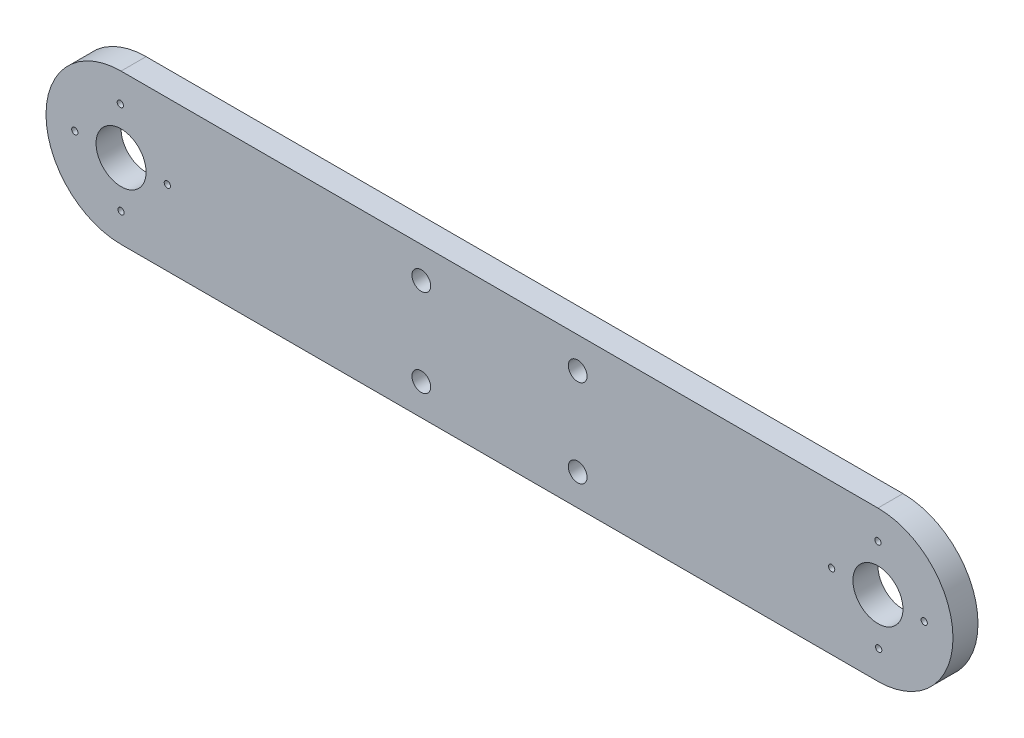
from build123d import *

# Parameters (mm, degrees)
SKETCH1_R           = 4
SKETCH1_R_2         = 0.5
SKETCH1_R_3         = 1.5
BOSS_EXTRUDE1_DEPTH = 4


with BuildPart() as part:
    # Sketch1 → Boss-Extrude1 (new body)
    with BuildSketch(Plane.XY):
        with BuildLine():
            Line((12, 24), (133, 24))
            ThreePointArc((133, 24), (145, 12), (133, 0))
            Line((133, 0), (12, 0))
            ThreePointArc((12, 0), (0, 12), (12, 24))
        make_face()
        with Locations((133, 12)):
            Circle(SKETCH1_R, mode=Mode.SUBTRACT)
        with Locations((133, 19.4)):
            Circle(SKETCH1_R_2, mode=Mode.SUBTRACT)
        with Locations((133.121025162, 4.600989734)):
            Circle(SKETCH1_R_2, mode=Mode.SUBTRACT)
        with Locations((140.4, 12)):
            Circle(SKETCH1_R_2, mode=Mode.SUBTRACT)
        with Locations((125.6, 12)):
            Circle(SKETCH1_R_2, mode=Mode.SUBTRACT)
        with Locations((60, 5)):
            Circle(SKETCH1_R_3, mode=Mode.SUBTRACT)
        with Locations((60, 19)):
            Circle(SKETCH1_R_3, mode=Mode.SUBTRACT)
        with Locations((85, 5)):
            Circle(SKETCH1_R_3, mode=Mode.SUBTRACT)
        with Locations((85, 19)):
            Circle(SKETCH1_R_3, mode=Mode.SUBTRACT)
        with Locations((12, 12)):
            Circle(SKETCH1_R, mode=Mode.SUBTRACT)
        with Locations((12, 4.6)):
            Circle(SKETCH1_R_2, mode=Mode.SUBTRACT)
        with Locations((11.878974838, 19.399010266)):
            Circle(SKETCH1_R_2, mode=Mode.SUBTRACT)
        with Locations((4.6, 12)):
            Circle(SKETCH1_R_2, mode=Mode.SUBTRACT)
        with Locations((19.4, 12)):
            Circle(SKETCH1_R_2, mode=Mode.SUBTRACT)
    extrude(amount=BOSS_EXTRUDE1_DEPTH)


solid = part.part
